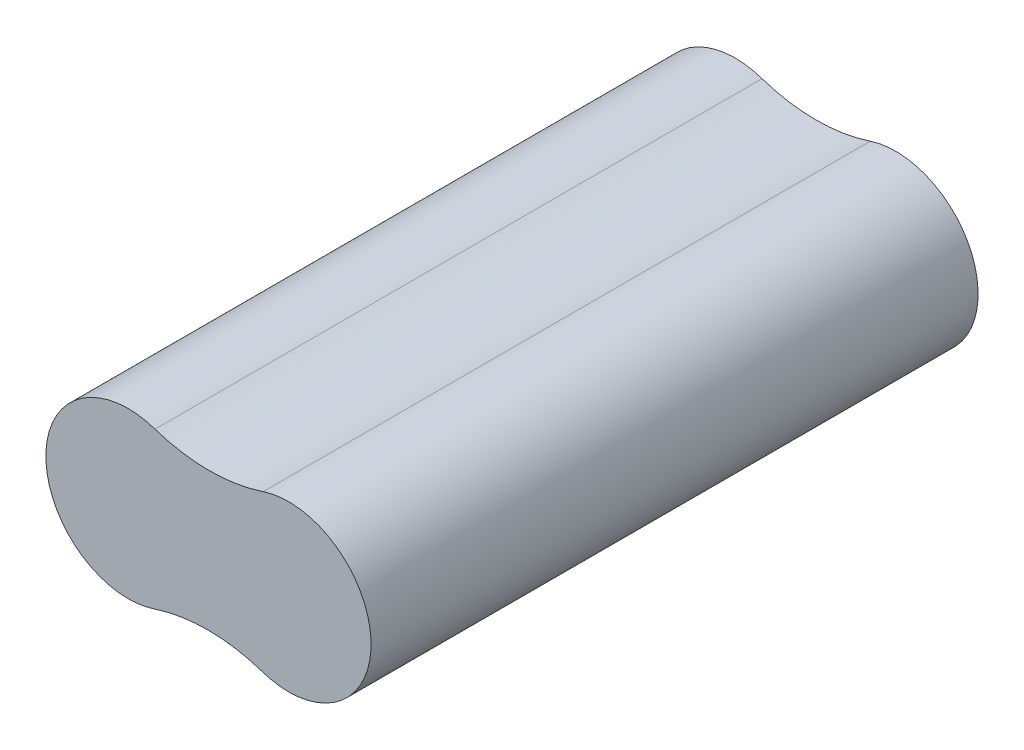
from build123d import *

# Parameters (mm, degrees)
EXTRUDE2_DEPTH = 70


with BuildPart() as part:
    # Sketch1 → Extrude2 (new body)
    with BuildSketch(Plane.XY):
        with BuildLine():
            ThreePointArc((6.00492643, -8.984603126), (18.591162436, -0.079511359), (6.155748964, 9.03500936))
            ThreePointArc((6.155748964, 9.03500936), (-0.083259924, 8.021388206), (-6.322268812, 9.03500936))
            ThreePointArc((-6.322268812, 9.03500936), (-18.908837564, 0.050406234), (-6.322268812, -8.934196893))
            ThreePointArc((-6.322268812, -8.934196893), (-0.154628652, -7.970769033), (6.00492643, -8.984603126))
        make_face()
    extrude(amount=EXTRUDE2_DEPTH)


solid = part.part
